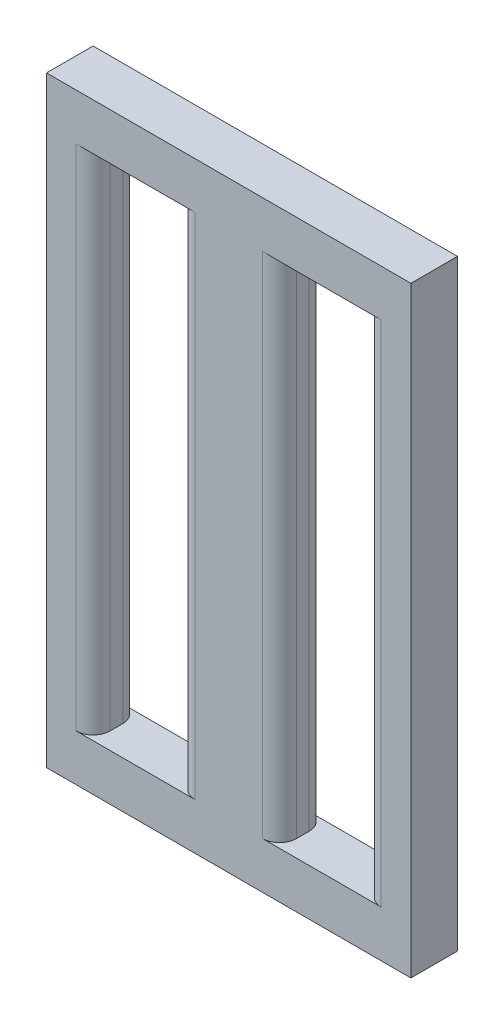
from build123d import *

# Parameters (mm, degrees)
SKETCH1_W           = 5
SKETCH1_H           = 30
BOSS_EXTRUDE1_DEPTH = 2.75
FILLET1_R           = 1


with BuildPart() as part:
    # Sketch1 → Boss-Extrude1 (new body)
    with BuildSketch(Plane.XY):
        Polygon((0, 30), (0, 32.75), (21.5, 32.75), (21.5, 30), (21.5, 0), (21.5, -2.75), (0, -2.75), (0, 0), align=None)
        with Locations((5.25, 15)):
            Rectangle(SKETCH1_W, SKETCH1_H, mode=Mode.SUBTRACT)
        with Locations((16.25, 15)):
            Rectangle(SKETCH1_W, SKETCH1_H, mode=Mode.SUBTRACT)
    extrude(amount=BOSS_EXTRUDE1_DEPTH)

    # Fillet1
    fillet1_edges = [part.edges().sort_by_distance(p)[0] for p in [
        (2.75, 15, 0),
        (7.75, 15, 0),
        (2.75, 15, 2.75),
        (7.75, 15, 2.75),
        (13.75, 15, 0),
        (18.75, 15, 0),
        (13.75, 15, 2.75),
        (18.75, 15, 2.75),
    ]]
    fillet(fillet1_edges, radius=FILLET1_R)


solid = part.part
